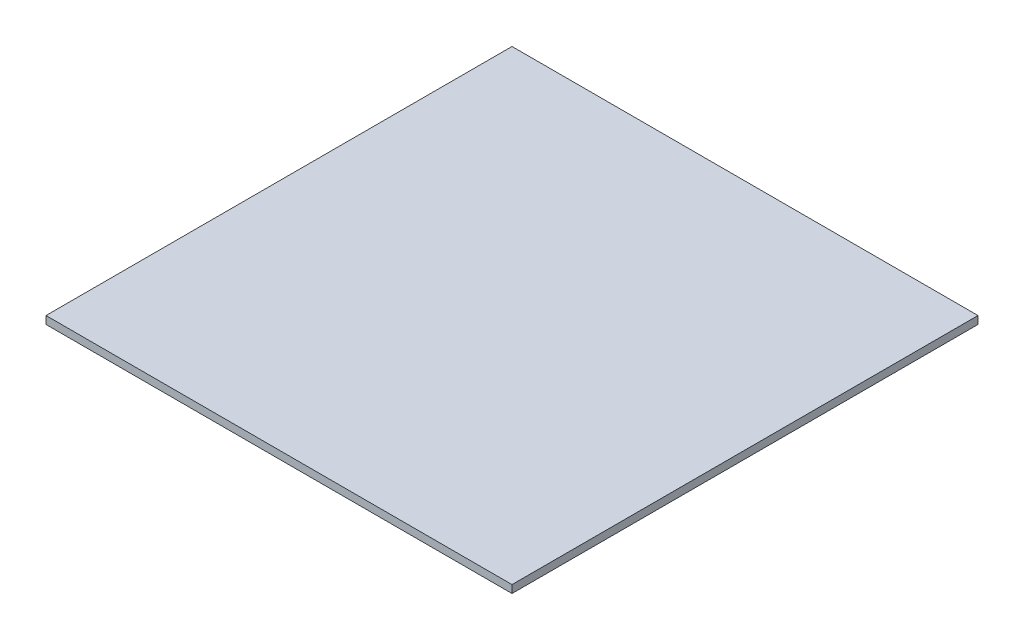
from build123d import *

# Parameters (mm, degrees)
SKETCH_1_W      = 300
SKETCH_1_H      = 300
EXTRUDE_1_DEPTH = 5


with BuildPart() as part:
    # Эскиз1 → Бобышка-Вытянуть1 (new body)
    with BuildSketch(Plane(origin=(0, 0, 0), x_dir=(1, 0, 0), z_dir=(0, 1, 0))):
        with Locations((150, -150)):
            Rectangle(SKETCH_1_W, SKETCH_1_H)
    extrude(amount=EXTRUDE_1_DEPTH)


solid = part.part
